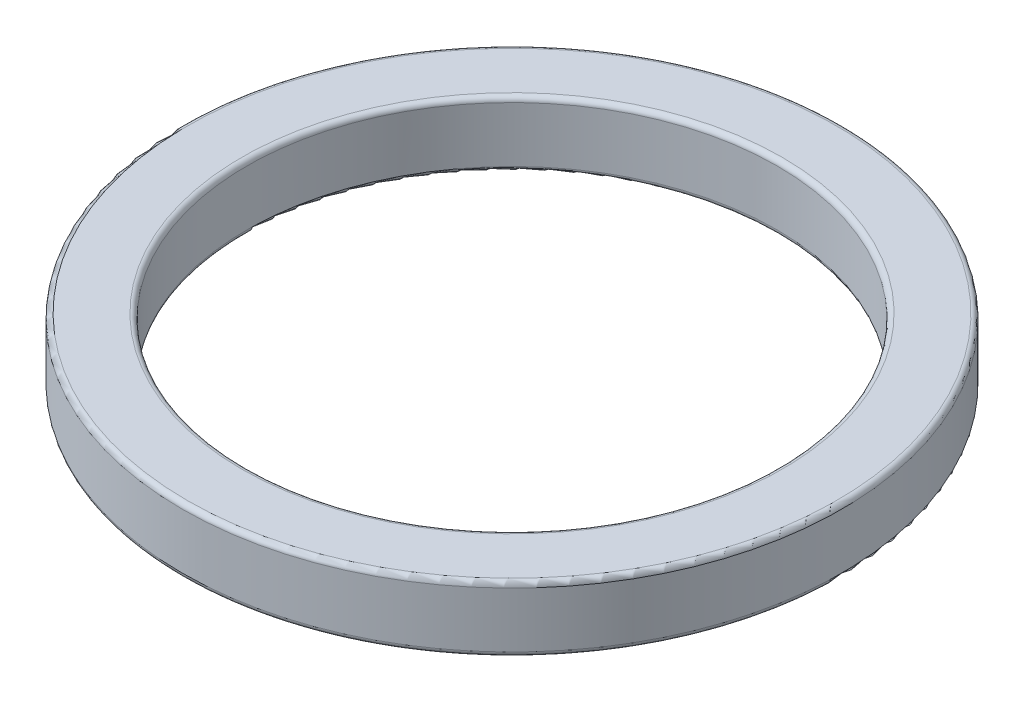
from build123d import *

# Parameters (mm, degrees)
ESQUISSE1_W = 1.28
ESQUISSE1_H = 1.3
CONG_1_R    = 0.1


with BuildPart() as part:
    # Esquisse1 → Révolution1 (revolve)
    with BuildSketch(Plane.XY):
        with Locations((5.91, 2.321727173)):
            Rectangle(ESQUISSE1_W, ESQUISSE1_H)
    revolve(axis=Axis((0, 0, 0), (0, 1, 0)))

    # Congé1
    cong_1_edges = [part.edges().sort_by_distance(p)[0] for p in [
        (-5.27, 2.971727173, 0),
        (-6.55, 2.971727173, 0),
        (-6.55, 1.671727173, 0),
        (-5.27, 1.671727173, 0),
    ]]
    fillet(cong_1_edges, radius=CONG_1_R)


solid = part.part
